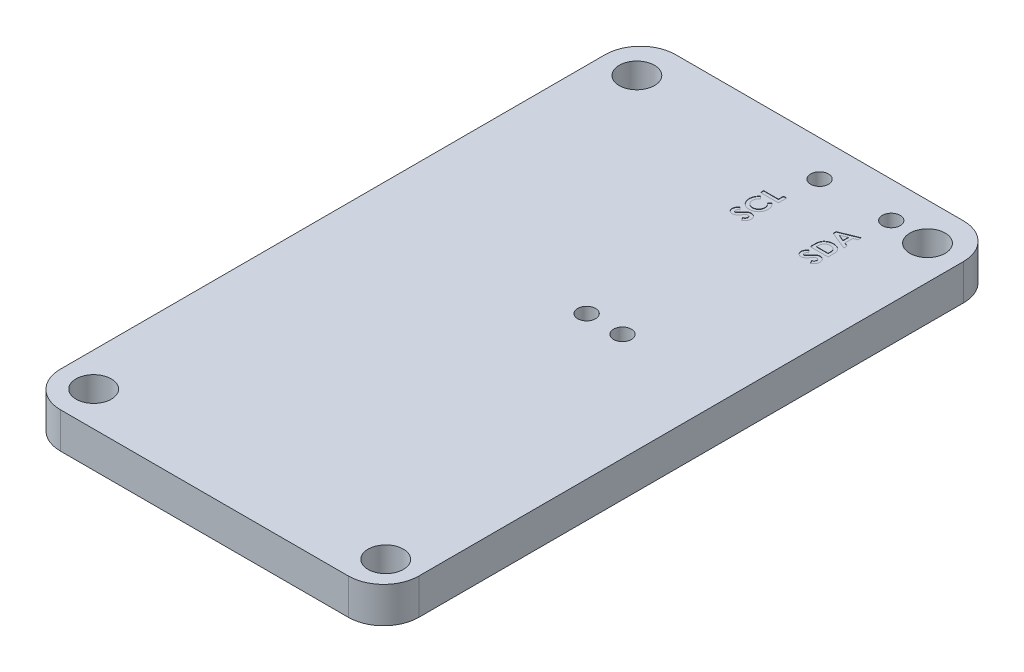
from build123d import *

# Parameters (mm, degrees)
SKETCH1_W             = 25.4
SKETCH1_H             = 43.6
BOSS_EXTRUDE1_DEPTH   = 1.27
FILLET1_R             = 2.5
SKETCH2_R             = 0.635
CUT_EXTRUDE1_DEPTH    = 26.357081851
CUT_EXTRUDE2_DEPTH    = 0.0254
F_2_5MM_DOWEL_HOLE1_D = 2.5


with BuildPart() as part:
    # Sketch1 → Boss-Extrude1 (new, symmetric)
    with BuildSketch(Plane(origin=(0, 0, 0), x_dir=(1, 0, 0), z_dir=(0, 1, 0))):
        Rectangle(SKETCH1_W, SKETCH1_H)
    extrude(amount=BOSS_EXTRUDE1_DEPTH, both=True)

    # Fillet1
    fillet1_edges = [part.edges().sort_by_distance(p)[0] for p in [
        (12.7, 0, 21.8),
        (-12.7, 0, 21.8),
        (-12.7, 0, -21.8),
        (12.7, 0, -21.8),
    ]]
    fillet(fillet1_edges, radius=FILLET1_R)

    # Sketch2 → Cut-Extrude1 (cut, through all)
    with BuildSketch(Plane(origin=(0, 1.27, 0), x_dir=(1, 0, 0), z_dir=(0, 1, 0))):
        with Locations(Location((7.62, 19.26, 0), (0, 0, 270))):
            Circle(SKETCH2_R)
        with Locations(Location((2.54, 19.26, 0), (0, 0, 270))):
            Circle(SKETCH2_R)
        with Locations(Location((5.08, 2.75, 0), (0, 0, 270))):
            Circle(SKETCH2_R)
        with Locations(Location((2.54, 2.75, 0), (0, 0, 270))):
            Circle(SKETCH2_R)
    extrude(amount=-CUT_EXTRUDE1_DEPTH, mode=Mode.SUBTRACT)

    # Sketch4 → Cut-Extrude2 (cut)
    with BuildSketch(Plane(origin=(0, 1.27, 0), x_dir=(1, 0, 0), z_dir=(0, 1, 0))):
        Polygon((1.27, 16.345512821), (1.27, 16.573461538), (2.312051282, 16.573461538), (2.312051282, 16.931666667), (2.54, 16.931666667), (2.54, 16.345512821), align=None)
        with BuildLine():
            Line((1.490316506, 16.117564103), (1.650084135, 15.95041867))
            add(Edge.make_bspline(
                [(1.650084135, 15.95041867), (1.635420859, 15.936241353), (1.606778889, 15.908548612), (1.568901397, 15.863902635), (1.537202986, 15.817591062), (1.511042354, 15.770076014), (1.490451693, 15.721264498), (1.475891836, 15.670992812), (1.4669163, 15.619334411), (1.465897197, 15.584362679), (1.465384615, 15.566772837)],
                knots=[0, 0, 0, 0, 1.115315123, 2.178559852, 3.196385012, 4.180486591, 5.141138664, 6.08807191, 7.038351522, 8, 8, 8, 8], degree=3))
            add(Edge.make_bspline(
                [(1.465384615, 15.566772837), (1.46579077, 15.552083737), (1.466592271, 15.523096416), (1.472482222, 15.480539456), (1.48246056, 15.439816089), (1.496330379, 15.400894007), (1.51379713, 15.363580775), (1.535751578, 15.328223845), (1.561460965, 15.294633206), (1.590880304, 15.263201336), (1.623260936, 15.234825157), (1.657363547, 15.209257816), (1.693791328, 15.188080565), (1.732013051, 15.1707936), (1.772042518, 15.157171073), (1.813877726, 15.147502619), (1.85761313, 15.141900711), (1.887345211, 15.141065503), (1.902455929, 15.140641026)],
                knots=[0, 0, 0, 0, 1.035268443, 2.04298821, 3.02163646, 3.985902049, 4.951223231, 5.920091634, 6.913651787, 7.92868536, 8.949353712, 9.945284791, 10.92850487, 11.913014323, 12.897904816, 13.904240668, 14.934873455, 16, 16, 16, 16], degree=3))
            add(Edge.make_bspline(
                [(1.902455929, 15.140641026), (1.913061324, 15.140765257), (1.933964774, 15.141010121), (1.964808259, 15.143617441), (1.994794863, 15.147959497), (2.023852517, 15.154008009), (2.052019163, 15.161761702), (2.079360756, 15.170718552), (2.105551302, 15.182158737), (2.131081185, 15.194742789), (2.155335848, 15.209220347), (2.178331261, 15.225073316), (2.20007257, 15.242155597), (2.220482471, 15.260695325), (2.239267149, 15.280925956), (2.256938086, 15.302358889), (2.273216541, 15.325207045), (2.287843291, 15.349479579), (2.301476973, 15.374441979), (2.312766973, 15.4006085), (2.322916137, 15.427247216), (2.330551333, 15.454825657), (2.337192348, 15.482857976), (2.341248221, 15.511734373), (2.344330148, 15.541180795), (2.344519896, 15.56108251), (2.344615385, 15.571097756)],
                knots=[0, 0, 0, 0, 1.103738238, 2.175490744, 3.219137561, 4.256155604, 5.262629953, 6.259184223, 7.247888397, 8.234817694, 9.220364322, 10.185094651, 11.140491148, 12.096499151, 13.05201798, 14.011605636, 14.986460005, 15.968997565, 16.960259839, 17.944382265, 18.933125845, 19.924977513, 20.920749559, 21.929466621, 22.958034467, 24, 24, 24, 24], degree=3))
            add(Edge.make_bspline(
                [(2.344615385, 15.571097756), (2.344125872, 15.588085892), (2.343164107, 15.621463161), (2.335588325, 15.67043742), (2.32325924, 15.717180247), (2.308279284, 15.75439262), (2.293754093, 15.78356422), (2.280696594, 15.805958381), (2.265643378, 15.828870011), (2.248531936, 15.852264217), (2.229437038, 15.876276783), (2.207985576, 15.900510334), (2.184870923, 15.925577488), (2.168374095, 15.941999037), (2.159915865, 15.95041867)],
                knots=[0, 0, 0, 0, 1.404693586, 2.759857621, 4.088769373, 5.395275838, 6.0697462, 6.783214465, 7.53810233, 8.336454657, 9.18000028, 10.074808326, 11.012918585, 12, 12, 12, 12], degree=3))
            Line((2.159915865, 15.95041867), (2.330114183, 16.112475962))
            add(Edge.make_bspline(
                [(2.330114183, 16.112475962), (2.341112565, 16.101084206), (2.362579055, 16.078849936), (2.393059467, 16.045310157), (2.420449506, 16.011812589), (2.44574331, 15.979166463), (2.468204009, 15.946837002), (2.487854034, 15.914827635), (2.505190364, 15.883500722), (2.519920629, 15.852205748), (2.532428154, 15.820747982), (2.543196313, 15.788381637), (2.552305787, 15.755007766), (2.559655936, 15.720422538), (2.565549764, 15.684948541), (2.569528064, 15.648253788), (2.572202542, 15.61057094), (2.572442866, 15.58501008), (2.572564103, 15.572115385)],
                knots=[0, 0, 0, 0, 1.244526981, 2.429050516, 3.560637417, 4.644440555, 5.67424972, 6.652764056, 7.595344123, 8.486817594, 9.369275933, 10.254498637, 11.166417451, 12.086725134, 13.032340136, 13.991389299, 14.986715468, 16, 16, 16, 16], degree=3))
            add(Edge.make_bspline(
                [(2.572564103, 15.572115385), (2.5719603, 15.548429426), (2.570778827, 15.502082589), (2.56202491, 15.434162507), (2.547349122, 15.369640253), (2.526593509, 15.308358856), (2.500079187, 15.250337801), (2.467573874, 15.195591933), (2.42916393, 15.144209489), (2.385299557, 15.096605539), (2.33685504, 15.0535455), (2.284838919, 15.015485413), (2.228995554, 14.984002107), (2.17014993, 14.95786084), (2.108033511, 14.937418712), (2.042579106, 14.92303092), (1.973849916, 14.914158074), (1.926906295, 14.913187372), (1.902964744, 14.912692308)],
                knots=[0, 0, 0, 0, 1.078019885, 2.10938526, 3.111377082, 4.085535484, 5.04941344, 6.010039228, 6.978205633, 7.964457913, 8.951525778, 9.924444315, 10.892603023, 11.863865945, 12.85144698, 13.863884204, 14.910567087, 16, 16, 16, 16], degree=3))
            add(Edge.make_bspline(
                [(1.902964744, 14.912692308), (1.887349893, 14.912899436), (1.856405076, 14.913309913), (1.810743776, 14.917704957), (1.766287949, 14.923674589), (1.723417488, 14.933480919), (1.681644413, 14.944881211), (1.641338391, 14.959568796), (1.60232964, 14.976632862), (1.564667425, 14.996116856), (1.52875845, 15.018432842), (1.49437371, 15.042729018), (1.461958624, 15.069594633), (1.431379547, 15.09875777), (1.40229012, 15.129948939), (1.375405747, 15.163702329), (1.350005186, 15.19944229), (1.326845979, 15.237416397), (1.305783078, 15.276759337), (1.287662104, 15.317279937), (1.272113644, 15.358455823), (1.25931254, 15.400411847), (1.249731327, 15.443222196), (1.242485709, 15.486600014), (1.238433832, 15.53090937), (1.237770661, 15.560659445), (1.237435897, 15.575677083)],
                knots=[0, 0, 0, 0, 1.071814294, 2.12407397, 3.147667899, 4.14936388, 5.141177959, 6.119239245, 7.091825145, 8.063277363, 9.028022524, 9.992609517, 10.952139039, 11.915934802, 12.892469547, 13.878248468, 14.87668965, 15.901326483, 16.93027266, 17.938917451, 18.9468897, 19.950817235, 20.948103127, 21.957084021, 22.968749718, 24, 24, 24, 24], degree=3))
            add(Edge.make_bspline(
                [(1.237435897, 15.575677083), (1.237627991, 15.588488596), (1.238010182, 15.613978419), (1.241190528, 15.651938087), (1.246199409, 15.689590017), (1.253703935, 15.72681923), (1.262792262, 15.763793145), (1.273986627, 15.800356962), (1.287641128, 15.836409854), (1.302745888, 15.872264372), (1.319941873, 15.90720545), (1.339189409, 15.940929428), (1.359984962, 15.973519867), (1.382686218, 16.004780301), (1.406959726, 16.03493091), (1.432804682, 16.063939525), (1.460689907, 16.091527786), (1.480391048, 16.108841456), (1.490316506, 16.117564103)],
                knots=[0, 0, 0, 0, 0.996333415, 1.982307736, 2.96084097, 3.949129141, 4.93457382, 5.921430247, 6.92116383, 7.931890485, 8.946633814, 9.948019707, 10.950686436, 11.952094051, 12.951305284, 13.960287133, 14.972390273, 16, 16, 16, 16], degree=3))
        make_face()
        with BuildLine():
            Line((1.439689503, 14.717307692), (1.595641026, 14.546854968))
            add(Edge.make_bspline(
                [(1.595641026, 14.546854968), (1.585341552, 14.539553504), (1.565567998, 14.525535712), (1.539090744, 14.502814333), (1.516503676, 14.480195552), (1.497901153, 14.457469821), (1.483396197, 14.434435707), (1.473126528, 14.411133194), (1.466598003, 14.387694391), (1.465785044, 14.371947133), (1.465384615, 14.364190705)],
                knots=[0, 0, 0, 0, 1.299362458, 2.494594718, 3.587462134, 4.587049575, 5.512617175, 6.380583204, 7.202344345, 8, 8, 8, 8], degree=3))
            add(Edge.make_bspline(
                [(1.465384615, 14.364190705), (1.465630801, 14.356952161), (1.466106122, 14.342976434), (1.471068521, 14.323145799), (1.479087491, 14.305324624), (1.490164419, 14.289987617), (1.503393485, 14.277649327), (1.517476471, 14.268055571), (1.532831564, 14.26248062), (1.543362355, 14.261764686), (1.548575721, 14.261410256)],
                knots=[0, 0, 0, 0, 1.184157716, 2.286297433, 3.324836695, 4.370048774, 5.362957217, 6.276446515, 7.146738784, 8, 8, 8, 8], degree=3))
            add(Edge.make_bspline(
                [(1.548575721, 14.261410256), (1.553861819, 14.26163461), (1.564507287, 14.262086427), (1.580109545, 14.266450362), (1.595354768, 14.273028059), (1.60463526, 14.279313317), (1.609379006, 14.282526042)],
                knots=[0, 0, 0, 0, 0.967525499, 1.948461899, 2.951351359, 4, 4, 4, 4], degree=3))
            add(Edge.make_bspline(
                [(1.609379006, 14.282526042), (1.613055747, 14.285458105), (1.62156802, 14.292246325), (1.635253325, 14.304808609), (1.651429041, 14.321211953), (1.670431262, 14.341048718), (1.692440405, 14.364249703), (1.717088823, 14.391174604), (1.744136791, 14.422020144), (1.763205472, 14.443655015), (1.773217147, 14.455014022)],
                knots=[0, 0, 0, 0, 0.473854981, 1.097054127, 1.870604305, 2.795416232, 3.865517794, 5.093525133, 6.47400653, 8, 8, 8, 8], degree=3))
            add(Edge.make_bspline(
                [(1.773217147, 14.455014022), (1.782460176, 14.465699516), (1.800001525, 14.485978364), (1.824939595, 14.514794569), (1.847275072, 14.5402841), (1.86717521, 14.56221514), (1.883820496, 14.58124304), (1.898234971, 14.59652624), (1.909788065, 14.608718828), (1.916774136, 14.61564279), (1.919755609, 14.618597756)],
                knots=[0, 0, 0, 0, 1.543627419, 2.929484142, 4.163674036, 5.24627963, 6.164986907, 6.925413438, 7.541394495, 8, 8, 8, 8], degree=3))
            add(Edge.make_bspline(
                [(1.919755609, 14.618597756), (1.931890107, 14.629808797), (1.955216872, 14.651360355), (1.991356871, 14.679386941), (2.02660575, 14.702352272), (2.061539563, 14.720325852), (2.096964895, 14.7337754), (2.133645747, 14.743197953), (2.171860624, 14.748926973), (2.197887507, 14.749554432), (2.211051683, 14.749871795)],
                knots=[0, 0, 0, 0, 1.206593015, 2.319495511, 3.336910718, 4.276265636, 5.184178927, 6.099356736, 7.038670786, 8, 8, 8, 8], degree=3))
            add(Edge.make_bspline(
                [(2.211051683, 14.749871795), (2.22387811, 14.749644463), (2.249044037, 14.749198429), (2.285870625, 14.743735373), (2.321115263, 14.735945374), (2.35439446, 14.723900675), (2.386254411, 14.709220644), (2.41619911, 14.690817195), (2.444530586, 14.669204529), (2.470746273, 14.644434389), (2.494523749, 14.617030836), (2.515733207, 14.587655705), (2.533105188, 14.555909236), (2.547982808, 14.522423717), (2.558569997, 14.486587796), (2.566899271, 14.449054605), (2.57177907, 14.409434026), (2.572298655, 14.382351611), (2.572564103, 14.368515625)],
                knots=[0, 0, 0, 0, 1.043169307, 2.046737005, 3.02462096, 3.976528701, 4.921503154, 5.875710796, 6.831116189, 7.817539083, 8.805892356, 9.780872653, 10.7604363, 11.74661763, 12.757588865, 13.796088471, 14.874055702, 16, 16, 16, 16], degree=3))
            add(Edge.make_bspline(
                [(2.572564103, 14.368515625), (2.57237155, 14.357653707), (2.571990185, 14.336140879), (2.568872248, 14.304435252), (2.563851174, 14.273815943), (2.556616256, 14.244335765), (2.547574176, 14.215764071), (2.536031116, 14.188379375), (2.522761249, 14.161984873), (2.507479447, 14.136634823), (2.489720779, 14.112489081), (2.470180436, 14.088870971), (2.447911791, 14.066558471), (2.423347189, 14.04505154), (2.396335973, 14.024627711), (2.367288021, 14.004589682), (2.33565462, 13.985836061), (2.313463923, 13.974250818), (2.302129407, 13.968333333)],
                knots=[0, 0, 0, 0, 1.016956594, 2.014157282, 2.980233409, 3.920138626, 4.854357287, 5.783465618, 6.699725051, 7.61900777, 8.551402113, 9.504102091, 10.486778735, 11.499758944, 12.559144124, 13.656050795, 14.802762778, 16, 16, 16, 16], degree=3))
            Line((2.302129407, 13.968333333), (2.181794872, 14.16880609))
            add(Edge.make_bspline(
                [(2.181794872, 14.16880609), (2.194661065, 14.176207944), (2.219326658, 14.190397931), (2.252468008, 14.21444419), (2.280848088, 14.239078356), (2.303965279, 14.264869947), (2.322128688, 14.291505347), (2.335109519, 14.319113212), (2.343144639, 14.347712939), (2.344125913, 14.367193773), (2.344615385, 14.376911058)],
                knots=[0, 0, 0, 0, 1.283663364, 2.460892379, 3.537111102, 4.529833553, 5.449777664, 6.316464042, 7.160231139, 8, 8, 8, 8], degree=3))
            add(Edge.make_bspline(
                [(2.344615385, 14.376911058), (2.344215656, 14.386794927), (2.343440123, 14.405971074), (2.336276761, 14.43334257), (2.325029759, 14.458437793), (2.308981836, 14.480129919), (2.290460095, 14.498497443), (2.269853811, 14.512053731), (2.247558309, 14.520569882), (2.232070387, 14.521470246), (2.224280849, 14.521923077)],
                knots=[0, 0, 0, 0, 1.13588714, 2.203786484, 3.234766741, 4.283437687, 5.291419208, 6.222934724, 7.106237994, 8, 8, 8, 8], degree=3))
            add(Edge.make_bspline(
                [(2.224280849, 14.521923077), (2.217033952, 14.521504906), (2.202312575, 14.520655431), (2.180424254, 14.514398462), (2.158545887, 14.504616911), (2.140600659, 14.493044646), (2.125575606, 14.481268417), (2.112557077, 14.470007686), (2.098173882, 14.456295095), (2.082407927, 14.440165413), (2.065120421, 14.421831754), (2.046313057, 14.401278675), (2.026151506, 14.378270822), (2.012417656, 14.362008826), (2.005236378, 14.353505609)],
                knots=[0, 0, 0, 0, 0.916159276, 1.861089862, 2.860218735, 3.940849679, 4.552606315, 5.27541173, 6.11797699, 7.06649574, 8.129236253, 9.306560635, 10.591630461, 12, 12, 12, 12], degree=3))
            add(Edge.make_bspline(
                [(2.005236378, 14.353505609), (1.991559286, 14.337340641), (1.965308808, 14.306315175), (1.926537523, 14.262472471), (1.890302745, 14.222965512), (1.85615419, 14.188138819), (1.824729991, 14.157538012), (1.795751176, 14.131403748), (1.769013649, 14.109876083), (1.737132543, 14.087530514), (1.698628665, 14.066041815), (1.652333378, 14.047434611), (1.605997356, 14.035476061), (1.574847135, 14.034126019), (1.559515224, 14.033461538)],
                knots=[0, 0, 0, 0, 1.345561566, 2.582539916, 3.71901348, 4.751744315, 5.681651107, 6.506005906, 7.230637833, 7.861516384, 8.978504332, 10.023243174, 11.027054763, 12, 12, 12, 12], degree=3))
            add(Edge.make_bspline(
                [(1.559515224, 14.033461538), (1.548642171, 14.033737023), (1.527221087, 14.034279757), (1.49572442, 14.039120858), (1.465333109, 14.046356465), (1.436156493, 14.056863188), (1.408236873, 14.07050492), (1.381415688, 14.08705251), (1.355974499, 14.106893392), (1.331663051, 14.128968513), (1.309673531, 14.153583701), (1.290275569, 14.179778176), (1.273803336, 14.207437053), (1.260580587, 14.2366669), (1.25008434, 14.267228972), (1.242731298, 14.299200482), (1.238334979, 14.332521367), (1.237739325, 14.355188222), (1.237435897, 14.366734776)],
                knots=[0, 0, 0, 0, 1.010608097, 1.99100651, 2.956992389, 3.912457524, 4.868345712, 5.842283282, 6.837666818, 7.864758285, 8.892394644, 9.901925088, 10.892014243, 11.880216914, 12.880338321, 13.892361018, 14.926363314, 16, 16, 16, 16], degree=3))
            add(Edge.make_bspline(
                [(1.237435897, 14.366734776), (1.237983279, 14.381698248), (1.239073721, 14.411507076), (1.24760104, 14.455580076), (1.261010048, 14.49862959), (1.277189979, 14.533316976), (1.292855657, 14.560923518), (1.307301919, 14.582061822), (1.323787872, 14.603696904), (1.342778162, 14.625493878), (1.3636499, 14.647981863), (1.386884194, 14.670828622), (1.412242026, 14.694277525), (1.430380065, 14.709496485), (1.439689503, 14.717307692)],
                knots=[0, 0, 0, 0, 1.282949271, 2.555771389, 3.837399776, 5.142782039, 5.830402679, 6.558840402, 7.337330299, 8.162747002, 9.037840561, 9.968992266, 10.957575255, 12, 12, 12, 12], degree=3))
        make_face()
        Polygon((6.35, 16.410895433), (6.35, 16.622307692), (7.62, 17.135192308), (7.62, 16.89172476), (7.359487179, 16.793014824), (7.359487179, 16.239679487), (7.62, 16.140969551), (7.62, 15.89775641), align=None)
        Polygon((6.690651042, 16.516474359), (7.131538462, 16.326177885), (7.131538462, 16.706770833), align=None, mode=Mode.SUBTRACT)
        with BuildLine():
            Line((6.35, 14.782435897), (6.35, 15.069661458))
            add(Edge.make_bspline(
                [(6.35, 15.069661458), (6.35015291, 15.092054543), (6.350448487, 15.13534063), (6.353906533, 15.198044683), (6.358983964, 15.256395281), (6.366756635, 15.31025951), (6.375772218, 15.359834393), (6.387866036, 15.404743886), (6.401656129, 15.445313636), (6.417925159, 15.481937661), (6.436883174, 15.515373383), (6.458003341, 15.547121273), (6.482056477, 15.577119515), (6.508579313, 15.605788949), (6.538056866, 15.632759626), (6.570000938, 15.658480695), (6.604874747, 15.682322389), (6.641842132, 15.705005392), (6.681059758, 15.72551915), (6.722193811, 15.743412016), (6.76497958, 15.758400979), (6.809462662, 15.770580287), (6.855495387, 15.780288601), (6.903170645, 15.787081313), (6.952444297, 15.791280635), (6.98583947, 15.791706621), (7.002808494, 15.791923077)],
                knots=[0, 0, 0, 0, 1.443572968, 2.79044287, 4.047742841, 5.218390556, 6.298195001, 7.294187071, 8.214052338, 9.058415274, 9.873579163, 10.689402867, 11.514245497, 12.34988967, 13.204999844, 14.087904451, 14.991805053, 15.926675376, 16.882870032, 17.842731001, 18.816259901, 19.80313118, 20.814314197, 21.847329874, 22.906167961, 24, 24, 24, 24], degree=3))
            add(Edge.make_bspline(
                [(7.002808494, 15.791923077), (7.026752891, 15.79135628), (7.073888837, 15.790240506), (7.143060297, 15.780841851), (7.209368039, 15.765641045), (7.272293381, 15.74426733), (7.331275961, 15.717769645), (7.385275649, 15.686115194), (7.434002592, 15.649768103), (7.477214208, 15.609151822), (7.514355076, 15.565174271), (7.546163868, 15.519472765), (7.5712465, 15.471601916), (7.587156471, 15.429421426), (7.597042028, 15.392844671), (7.602915455, 15.360734055), (7.608156573, 15.324234999), (7.612837861, 15.28310548), (7.615957789, 15.237349548), (7.618142526, 15.186959457), (7.619757486, 15.132001322), (7.619917044, 15.093831408), (7.62, 15.073986378)],
                knots=[0, 0, 0, 0, 1.315448733, 2.589537832, 3.828572084, 5.048874227, 6.235690825, 7.376293813, 8.481764604, 9.569767924, 10.627792487, 11.639989165, 12.623927547, 13.589954798, 14.111118089, 14.704320463, 15.382530461, 16.137544902, 16.978618851, 17.902349489, 18.90940453, 20, 20, 20, 20], degree=3))
            Line((7.62, 15.073986378), (7.62, 14.782435897))
            Line((7.62, 14.782435897), (6.35, 14.782435897))
        make_face()
        with BuildLine():
            Line((6.577948718, 15.010384615), (7.392051282, 15.010384615))
            Line((7.392051282, 15.010384615), (7.392051282, 15.129447115))
            add(Edge.make_bspline(
                [(7.392051282, 15.129447115), (7.391982693, 15.143611268), (7.391850795, 15.170849524), (7.390038522, 15.210223446), (7.387095606, 15.246560221), (7.38274259, 15.279907445), (7.377504798, 15.31034178), (7.37102634, 15.337752212), (7.363148041, 15.362192764), (7.353863386, 15.383864985), (7.343262893, 15.403651244), (7.330884786, 15.421981613), (7.317128782, 15.439672653), (7.301602762, 15.456397398), (7.284508926, 15.472218106), (7.265760136, 15.48704146), (7.245413337, 15.501065232), (7.223361022, 15.513929481), (7.19983605, 15.525684899), (7.175066298, 15.536113272), (7.148845487, 15.544759933), (7.121419075, 15.551946507), (7.092548285, 15.55708213), (7.062446957, 15.561330878), (7.030995835, 15.563521231), (7.00959544, 15.563821844), (6.998737981, 15.563974359)],
                knots=[0, 0, 0, 0, 1.502695833, 2.889746668, 4.180916226, 5.369476429, 6.456726991, 7.456222963, 8.355346258, 9.177624335, 9.954596642, 10.733182277, 11.52153258, 12.330160087, 13.151502329, 13.990398686, 14.863901178, 15.771270193, 16.696748626, 17.652564526, 18.61995629, 19.623816541, 20.657945923, 21.72937045, 22.847999446, 24, 24, 24, 24], degree=3))
            add(Edge.make_bspline(
                [(6.998737981, 15.563974359), (6.982099574, 15.56367169), (6.949655969, 15.563081508), (6.902407459, 15.557354347), (6.857971597, 15.548126219), (6.816462534, 15.534683387), (6.777616379, 15.518152219), (6.741933713, 15.497132493), (6.708829658, 15.47290116), (6.689413318, 15.453728605), (6.679711538, 15.444148638)],
                knots=[0, 0, 0, 0, 1.138242922, 2.219485503, 3.251901297, 4.239342788, 5.201071, 6.134757343, 7.067992642, 8, 8, 8, 8], degree=3))
            add(Edge.make_bspline(
                [(6.679711538, 15.444148638), (6.671444031, 15.43470267), (6.654558582, 15.415410351), (6.634325497, 15.381539378), (6.616548748, 15.34421532), (6.602453768, 15.302584315), (6.591306858, 15.257048707), (6.583619106, 15.207337286), (6.578679038, 15.153716267), (6.578197374, 15.116568875), (6.577948718, 15.097391827)],
                knots=[0, 0, 0, 0, 0.813307809, 1.661089106, 2.549956539, 3.493439533, 4.508053171, 5.589449661, 6.755572447, 8, 8, 8, 8], degree=3))
            Line((6.577948718, 15.097391827), (6.577948718, 15.010384615))
        make_face(mode=Mode.SUBTRACT)
        with BuildLine():
            Line((6.519689503, 14.521923077), (6.675641026, 14.351470353))
            add(Edge.make_bspline(
                [(6.675641026, 14.351470353), (6.665341552, 14.344168889), (6.645567998, 14.330151096), (6.619090744, 14.307429717), (6.596503676, 14.284810937), (6.577901153, 14.262085205), (6.563396197, 14.239051091), (6.553126528, 14.215748579), (6.546598003, 14.192309775), (6.545785044, 14.176562517), (6.545384615, 14.16880609)],
                knots=[0, 0, 0, 0, 1.299362458, 2.494594718, 3.587462134, 4.587049575, 5.512617175, 6.380583204, 7.202344345, 8, 8, 8, 8], degree=3))
            add(Edge.make_bspline(
                [(6.545384615, 14.16880609), (6.545630801, 14.161567545), (6.546106122, 14.147591818), (6.551068521, 14.127761184), (6.559087491, 14.109940009), (6.570164419, 14.094603001), (6.583393485, 14.082264712), (6.597476471, 14.072670955), (6.612831564, 14.067096005), (6.623362355, 14.066380071), (6.628575721, 14.066025641)],
                knots=[0, 0, 0, 0, 1.184157716, 2.286297433, 3.324836695, 4.370048774, 5.362957217, 6.276446515, 7.146738784, 8, 8, 8, 8], degree=3))
            add(Edge.make_bspline(
                [(6.628575721, 14.066025641), (6.633861819, 14.066249995), (6.644507287, 14.066701811), (6.660109545, 14.071065747), (6.675354768, 14.077643444), (6.68463526, 14.083928702), (6.689379006, 14.087141426)],
                knots=[0, 0, 0, 0, 0.967525499, 1.948461899, 2.951351359, 4, 4, 4, 4], degree=3))
            add(Edge.make_bspline(
                [(6.689379006, 14.087141426), (6.693055747, 14.090073489), (6.70156802, 14.09686171), (6.715253325, 14.109423993), (6.731429041, 14.125827338), (6.750431262, 14.145664102), (6.772440405, 14.168865088), (6.797088823, 14.195789988), (6.824136791, 14.226635529), (6.843205472, 14.248270399), (6.853217147, 14.259629407)],
                knots=[0, 0, 0, 0, 0.473854981, 1.097054127, 1.870604305, 2.795416232, 3.865517794, 5.093525133, 6.47400653, 8, 8, 8, 8], degree=3))
            add(Edge.make_bspline(
                [(6.853217147, 14.259629407), (6.862460176, 14.270314901), (6.880001525, 14.290593748), (6.904939595, 14.319409954), (6.927275072, 14.344899485), (6.94717521, 14.366830525), (6.963820496, 14.385858424), (6.978234971, 14.401141624), (6.989788065, 14.413334213), (6.996774136, 14.420258175), (6.999755609, 14.423213141)],
                knots=[0, 0, 0, 0, 1.543627419, 2.929484142, 4.163674036, 5.24627963, 6.164986907, 6.925413438, 7.541394495, 8, 8, 8, 8], degree=3))
            add(Edge.make_bspline(
                [(6.999755609, 14.423213141), (7.011890107, 14.434424182), (7.035216872, 14.455975739), (7.071356871, 14.484002326), (7.10660575, 14.506967657), (7.141539563, 14.524941236), (7.176964895, 14.538390785), (7.213645747, 14.547813338), (7.251860624, 14.553542358), (7.277887507, 14.554169816), (7.291051683, 14.554487179)],
                knots=[0, 0, 0, 0, 1.206593015, 2.319495511, 3.336910718, 4.276265636, 5.184178927, 6.099356736, 7.038670786, 8, 8, 8, 8], degree=3))
            add(Edge.make_bspline(
                [(7.291051683, 14.554487179), (7.30387811, 14.554259848), (7.329044037, 14.553813814), (7.365870625, 14.548350758), (7.401115263, 14.540560758), (7.43439446, 14.52851606), (7.466254411, 14.513836028), (7.49619911, 14.49543258), (7.524530586, 14.473819914), (7.550746273, 14.449049774), (7.574523749, 14.42164622), (7.595733207, 14.392271089), (7.613105188, 14.36052462), (7.627982808, 14.327039102), (7.638569997, 14.291203181), (7.646899271, 14.25366999), (7.65177907, 14.21404941), (7.652298655, 14.186966996), (7.652564103, 14.17313101)],
                knots=[0, 0, 0, 0, 1.043169307, 2.046737005, 3.02462096, 3.976528701, 4.921503154, 5.875710796, 6.831116189, 7.817539083, 8.805892356, 9.780872653, 10.7604363, 11.74661763, 12.757588865, 13.796088471, 14.874055702, 16, 16, 16, 16], degree=3))
            add(Edge.make_bspline(
                [(7.652564103, 14.17313101), (7.65237155, 14.162269091), (7.651990185, 14.140756264), (7.648872248, 14.109050637), (7.643851174, 14.078431328), (7.636616256, 14.048951149), (7.627574176, 14.020379456), (7.616031116, 13.992994759), (7.602761249, 13.966600258), (7.587479447, 13.941250207), (7.569720779, 13.917104465), (7.550180436, 13.893486356), (7.527911791, 13.871173855), (7.503347189, 13.849666925), (7.476335973, 13.829243095), (7.447288021, 13.809205067), (7.41565462, 13.790451446), (7.393463923, 13.778866203), (7.382129407, 13.772948718)],
                knots=[0, 0, 0, 0, 1.016956594, 2.014157282, 2.980233409, 3.920138626, 4.854357287, 5.783465618, 6.699725051, 7.61900777, 8.551402113, 9.504102091, 10.486778735, 11.499758944, 12.559144124, 13.656050795, 14.802762778, 16, 16, 16, 16], degree=3))
            Line((7.382129407, 13.772948718), (7.261794872, 13.973421474))
            add(Edge.make_bspline(
                [(7.261794872, 13.973421474), (7.274661065, 13.980823329), (7.299326658, 13.995013316), (7.332468008, 14.019059575), (7.360848088, 14.04369374), (7.383965279, 14.069485331), (7.402128688, 14.096120732), (7.415109519, 14.123728597), (7.423144639, 14.152328323), (7.424125913, 14.171809158), (7.424615385, 14.181526442)],
                knots=[0, 0, 0, 0, 1.283663364, 2.460892379, 3.537111102, 4.529833553, 5.449777664, 6.316464042, 7.160231139, 8, 8, 8, 8], degree=3))
            add(Edge.make_bspline(
                [(7.424615385, 14.181526442), (7.424215656, 14.191410312), (7.423440123, 14.210586459), (7.416276761, 14.237957954), (7.405029759, 14.263053178), (7.388981836, 14.284745304), (7.370460095, 14.303112828), (7.349853811, 14.316669115), (7.327558309, 14.325185267), (7.312070387, 14.32608563), (7.304280849, 14.326538462)],
                knots=[0, 0, 0, 0, 1.13588714, 2.203786484, 3.234766741, 4.283437687, 5.291419208, 6.222934724, 7.106237994, 8, 8, 8, 8], degree=3))
            add(Edge.make_bspline(
                [(7.304280849, 14.326538462), (7.297033952, 14.32612029), (7.282312575, 14.325270816), (7.260424254, 14.319013846), (7.238545887, 14.309232295), (7.220600659, 14.29766003), (7.205575606, 14.285883802), (7.192557077, 14.274623071), (7.178173882, 14.26091048), (7.162407927, 14.244780797), (7.145120421, 14.226447138), (7.126313057, 14.20589406), (7.106151506, 14.182886207), (7.092417656, 14.166624211), (7.085236378, 14.158120994)],
                knots=[0, 0, 0, 0, 0.916159276, 1.861089862, 2.860218735, 3.940849679, 4.552606315, 5.27541173, 6.11797699, 7.06649574, 8.129236253, 9.306560635, 10.591630461, 12, 12, 12, 12], degree=3))
            add(Edge.make_bspline(
                [(7.085236378, 14.158120994), (7.071559286, 14.141956026), (7.045308808, 14.11093056), (7.006537523, 14.067087856), (6.970302745, 14.027580897), (6.93615419, 13.992754204), (6.904729991, 13.962153397), (6.875751176, 13.936019133), (6.849013649, 13.914491468), (6.817132543, 13.892145899), (6.778628665, 13.8706572), (6.732333378, 13.852049996), (6.685997356, 13.840091445), (6.654847135, 13.838741404), (6.639515224, 13.838076923)],
                knots=[0, 0, 0, 0, 1.345561566, 2.582539916, 3.71901348, 4.751744315, 5.681651107, 6.506005906, 7.230637833, 7.861516384, 8.978504332, 10.023243174, 11.027054763, 12, 12, 12, 12], degree=3))
            add(Edge.make_bspline(
                [(6.639515224, 13.838076923), (6.628642171, 13.838352408), (6.607221087, 13.838895142), (6.57572442, 13.843736242), (6.545333109, 13.85097185), (6.516156493, 13.861478572), (6.488236873, 13.875120305), (6.461415688, 13.891667894), (6.435974499, 13.911508777), (6.411663051, 13.933583897), (6.389673531, 13.958199086), (6.370275569, 13.98439356), (6.353803336, 14.012052437), (6.340580587, 14.041282284), (6.33008434, 14.071844357), (6.322731298, 14.103815867), (6.318334979, 14.137136752), (6.317739325, 14.159803607), (6.317435897, 14.17135016)],
                knots=[0, 0, 0, 0, 1.010608097, 1.99100651, 2.956992389, 3.912457524, 4.868345712, 5.842283282, 6.837666818, 7.864758285, 8.892394644, 9.901925088, 10.892014243, 11.880216914, 12.880338321, 13.892361018, 14.926363314, 16, 16, 16, 16], degree=3))
            add(Edge.make_bspline(
                [(6.317435897, 14.17135016), (6.317983279, 14.186313632), (6.319073721, 14.21612246), (6.32760104, 14.26019546), (6.341010048, 14.303244975), (6.357189979, 14.337932361), (6.372855657, 14.365538903), (6.387301919, 14.386677207), (6.403787872, 14.408312288), (6.422778162, 14.430109263), (6.4436499, 14.452597248), (6.466884194, 14.475444006), (6.492242026, 14.498892909), (6.510380065, 14.51411187), (6.519689503, 14.521923077)],
                knots=[0, 0, 0, 0, 1.282949271, 2.555771389, 3.837399776, 5.142782039, 5.830402679, 6.558840402, 7.337330299, 8.162747002, 9.037840561, 9.968992266, 10.957575255, 12, 12, 12, 12], degree=3))
        make_face()
    extrude(amount=-CUT_EXTRUDE2_DEPTH, mode=Mode.SUBTRACT)

    # Ø2.5mm Dowel Hole1 (through all)
    with Locations(Plane(origin=(0, 1.27, 0), x_dir=(1, 0, 0), z_dir=(0, 1, 0))):
        with Locations((-10.3, 19.15), (-10.3, -19.35), (10.5, -19.45), (10.3, 19.15)):
            Hole(F_2_5MM_DOWEL_HOLE1_D / 2)


solid = part.part
